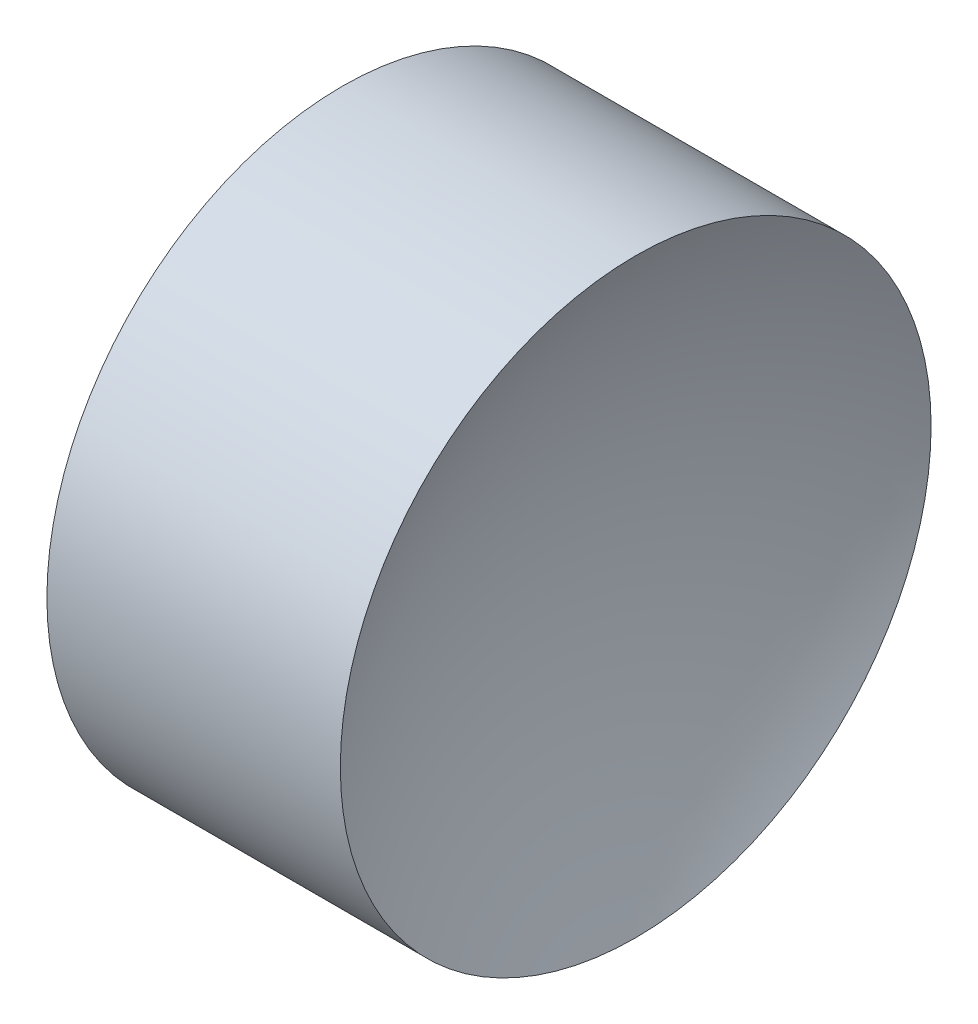
from build123d import *


with BuildPart() as part:
    # 草图1 → 旋转1 (revolve)
    with BuildSketch(Plane.XY, mode=Mode.PRIVATE) as revolve_1_sk:
        with BuildLine():
            Line((11.514895005, 6.522260287), (12.514895005, 6.522260287))
            ThreePointArc((12.514895005, 6.522260287), (12.64007375, 7.552244504), (13.008321743, 8.522260287))
            Line((13.008321743, 8.522260287), (12.014895005, 8.522260287))
            Line((12.014895005, 8.522260287), (11.021468267, 8.522260287))
            ThreePointArc((11.021468267, 8.522260287), (11.389716261, 7.552244504), (11.514895005, 6.522260287))
        make_face()
    revolve(revolve_1_sk.sketch.rotate(Axis((10.612465279, 6.522260287, 0), (1, 0, 0)), 90), axis=Axis((10.612465279, 6.522260287, 0), (1, 0, 0)))  # turned: the seam where the file's is


solid = part.part
